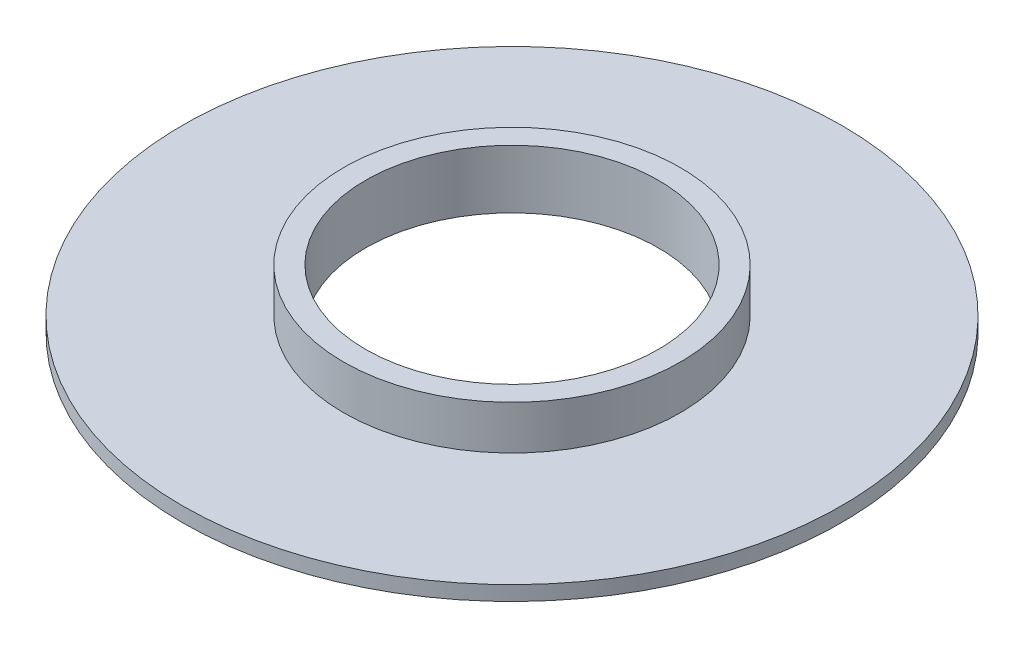
from build123d import *

# Parameters (mm, degrees)
ESQUISSE4_R             = 22.5
ESQUISSE4_R_2           = 10
BOSS_EXTRU_1_DEPTH      = 1
ESQUISSE5_R             = 11.5
BOSS_EXTRU_2_DEPTH      = 3
ENL_V_MAT_EXTRU_1_REACH = 6
ESQUISSE6_R             = 10


with BuildPart() as part:
    # Esquisse4 → Boss.-Extru.1 (new body)
    with BuildSketch(Plane(origin=(0, 0, 0), x_dir=(1, 0, 0), z_dir=(0, 1, 0))):
        with Locations(Location((0, 0, 0), (0, 0, 270))):  # turned: the seam where the file's is
            Circle(ESQUISSE4_R)
        with Locations(Location((0, 0, 0), (0, 0, 270))):  # turned: the seam where the file's is
            Circle(ESQUISSE4_R_2, mode=Mode.SUBTRACT)
    extrude(amount=BOSS_EXTRU_1_DEPTH)

    # Esquisse5 → Boss.-Extru.2 (add)
    with BuildSketch(Plane(origin=(0, 1, 0), x_dir=(1, 0, 0), z_dir=(0, 1, 0))):
        with Locations(Location((0, 0, 0), (0, 0, 270))):  # turned: the seam where the file's is
            Circle(ESQUISSE5_R)
    extrude(amount=BOSS_EXTRU_2_DEPTH)

    # Esquisse6 → Enlèv. mat.-Extru.1 (cut, up to next)
    with BuildSketch(Plane(origin=(0, 4, 0), x_dir=(1, 0, 0), z_dir=(0, 1, 0)), mode=Mode.PRIVATE) as enl_v_mat_extru_1_sk1:
        with Locations(Location((0, 0, 0), (0, 0, 270))):  # turned: the seam where the file's is
            Circle(ESQUISSE6_R)
    enl_v_mat_extru_1_tool1 = extrude(enl_v_mat_extru_1_sk1.sketch, amount=-ENL_V_MAT_EXTRU_1_REACH, mode=Mode.PRIVATE) & part.part
    add(enl_v_mat_extru_1_tool1.solids().sort_by_distance((0, 4, 0))[0], mode=Mode.SUBTRACT)


solid = part.part
